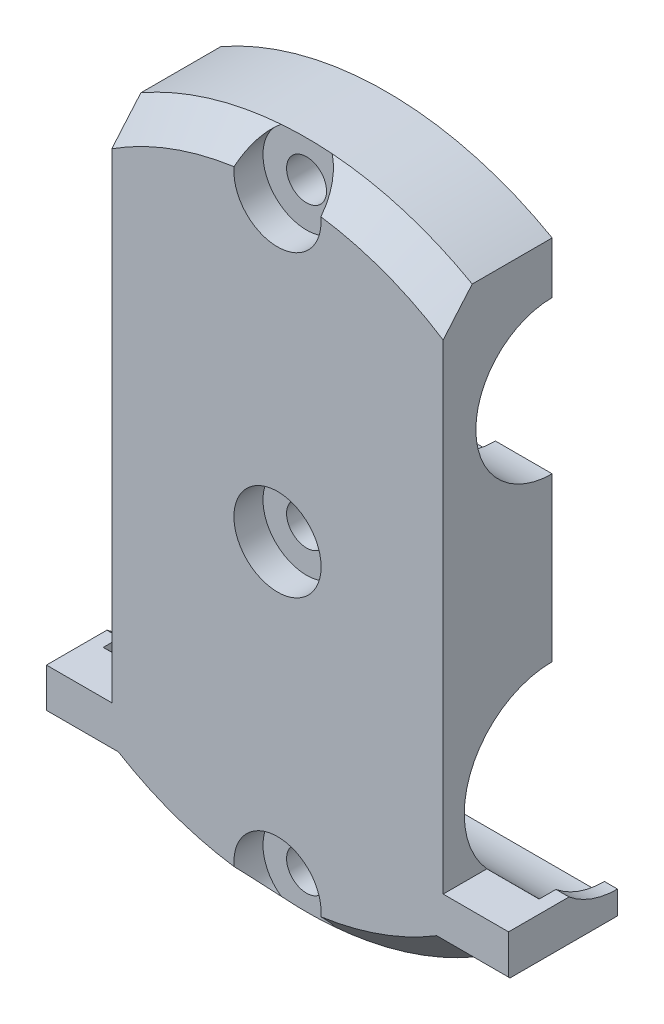
from build123d import *

# Parameters (mm, degrees)
BOSS_EXTRUDE1_DEPTH     = 15
SKETCH7_R               = 12.1
CUT_EXTRUDE3_DEPTH      = 71.5
SKETCH8_R               = 12.1
CUT_EXTRUDE4_DEPTH      = 71.5
CUT_EXTRUDE4_DEPTH_BACK = 71.5
BOSS_EXTRUDE4_DEPTH     = 8
BOSS_EXTRUDE5_DEPTH     = 2
SKETCH11_R              = 2.75
CUT_EXTRUDE5_DEPTH      = 24
SKETCH12_R              = 6
CUT_EXTRUDE6_DEPTH      = 4
CHAMFER1_SIZE           = 4
CUT_EXTRUDE7_DEPTH      = 28


with BuildPart() as part:
    # Sketch1 → Boss-Extrude1 (new body)
    with BuildSketch(Plane.XY):
        with BuildLine():
            Line((-23, -30.39874498), (-32, -30.39874498))
            Line((-32, -30.39874498), (-32, -39.99874498))
            Line((-32, -39.99874498), (-23, -39.99874498))
            ThreePointArc((-23, -39.99874498), (0, -46.14), (23, -39.99874498))
            Line((23, -39.99874498), (32, -39.99874498))
            Line((32, -39.99874498), (32, -30.39874498))
            Line((32, -30.39874498), (23, -30.39874498))
            Line((23, -30.39874498), (23, 39.99874498))
            ThreePointArc((23, 39.99874498), (0, 46.14), (-23, 39.99874498))
            Line((-23, 39.99874498), (-23, -30.39874498))
        make_face()
    extrude(amount=BOSS_EXTRUDE1_DEPTH)

    # Sketch7 → Cut-Extrude3 (cut)
    with BuildSketch(Plane.ZY.offset(23)):
        with Locations((0, 22.49874498)):
            Circle(SKETCH7_R)
    extrude(amount=-CUT_EXTRUDE3_DEPTH, mode=Mode.SUBTRACT)

    # Sketch8 → Cut-Extrude4 (cut, two sides)
    with BuildSketch(Plane.ZY.offset(23)) as cut_extrude4_sk:
        with Locations((0, -22.49874498)):
            Circle(SKETCH8_R)
    extrude(amount=CUT_EXTRUDE4_DEPTH, mode=Mode.SUBTRACT)
    extrude(cut_extrude4_sk.sketch, amount=-CUT_EXTRUDE4_DEPTH_BACK, mode=Mode.SUBTRACT)

    # Sketch9 → Boss-Extrude4 (add)
    with BuildSketch(Plane.ZY.offset(23)):
        with BuildLine():
            Line((0, 34.59874498), (0, 32.99874498))
            ThreePointArc((0, 32.99874498), (10.5, 22.49874498), (0, 11.99874498))
            Line((0, 11.99874498), (0, 10.39874498))
            ThreePointArc((0, 10.39874498), (12.1, 22.49874498), (0, 34.59874498))
        make_face()
    boss_extrude4 = extrude(amount=-BOSS_EXTRUDE4_DEPTH)

    # Sketch10 → Boss-Extrude5 (add)
    with BuildSketch(Plane.ZY.offset(32)):
        with BuildLine():
            Line((0, -32.99874498), (0, -34.59874498))
            ThreePointArc((0, -34.59874498), (5.040833264, -33.49874498), (9.16515139, -30.39874498))
            Line((9.16515139, -30.39874498), (6.916646586, -30.39874498))
            ThreePointArc((6.916646586, -30.39874498), (3.69459064, -32.327274881), (0, -32.99874498))
        make_face()
    boss_extrude5 = extrude(amount=-BOSS_EXTRUDE5_DEPTH)

    # Mirror1: Boss-Extrude4, Boss-Extrude5 across plane
    add(boss_extrude4.mirror(Plane(origin=(0, 0, 0), x_dir=(0, 0, 1), z_dir=(1, 0, 0))))
    add(boss_extrude5.mirror(Plane(origin=(0, 0, 0), x_dir=(0, 0, 1), z_dir=(1, 0, 0))))

    # Sketch11 → Cut-Extrude5 (cut)
    with BuildSketch(Plane(origin=(0, 0, 0), x_dir=(-1, 0, 0), z_dir=(0, 0, -1))):
        Circle(SKETCH11_R)
        with Locations((0, 41.14108798)):
            Circle(SKETCH11_R)
        with Locations((0, -41.14108798)):
            Circle(SKETCH11_R)
    extrude(amount=-CUT_EXTRUDE5_DEPTH, mode=Mode.SUBTRACT)

    # Sketch12 → Cut-Extrude6 (cut)
    with BuildSketch(Plane.XY.offset(15)):
        Circle(SKETCH12_R)
        with Locations((0, -41.14108798)):
            Circle(SKETCH12_R)
        with Locations((0, 41.14108798)):
            Circle(SKETCH12_R)
    extrude(amount=-CUT_EXTRUDE6_DEPTH, mode=Mode.SUBTRACT)

    # Chamfer1
    chamfer1_edges = [part.edges().sort_by_distance(p)[0] for p in [
        (-13.591823685, 44.092651643, 15),
        (13.591823685, 44.092651643, 15),
        (13.591823685, -44.092651643, 15),
        (27.5, -39.99874498, 15),
        (32, -39.99874498, 7.5),
        (-13.591823685, -44.092651643, 15),
        (-27.5, -39.99874498, 15),
        (-32, -39.99874498, 7.5),
    ]]
    chamfer(chamfer1_edges, length=CHAMFER1_SIZE)

    # Sketch13 → Cut-Extrude7 (cut)
    with BuildSketch(Plane.XY.offset(15)):
        Polygon((31.8, -38.311994276), (31.8, -30.59874498), (22.8, -30.59874498), (22.8, 43.889056734), (37.227618098, 33.583615236), (38.561263468, -37.220829882), align=None)
        Polygon((-37.227618098, 33.583615236), (-38.561263468, -37.220829882), (-31.8, -38.311994276), (-31.8, -30.59874498), (-22.8, -30.59874498), (-22.8, 43.889056734), align=None)
    extrude(amount=-CUT_EXTRUDE7_DEPTH, mode=Mode.SUBTRACT)


solid = part.part
